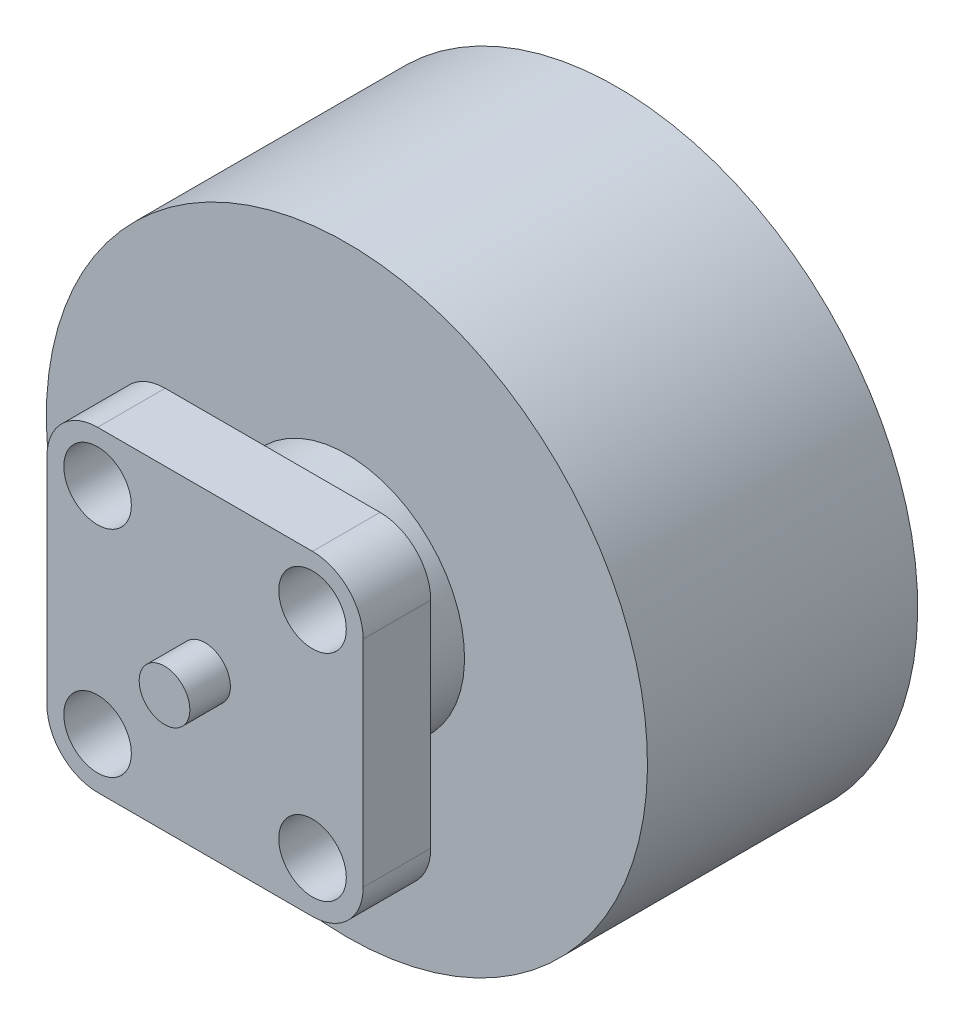
from build123d import *

# Parameters (mm, degrees)
SKETCH1_W           = 1.2
SKETCH1_H           = 0.75
SKETCH1_W_2         = 4.2
SKETCH1_W_3         = 8
SKETCH1_H_2         = 2.733563445
SKETCH2_W           = 9.36396103
SKETCH2_H           = 9.36396103
SKETCH2_R           = 1
BOSS_EXTRUDE1_DEPTH = 2
FILLET1_R           = 1.5
SKETCH3_R           = 1
CUT_EXTRUDE1_DEPTH  = 2


with BuildPart() as part:
    # Sketch1 → Revolve1 (revolve)
    with BuildSketch(Plane(origin=(0, 0, 0), x_dir=(0, 0, -1), z_dir=(1, 0, 0))):
        with Locations((-0.6, 0.375)):
            Rectangle(SKETCH1_W, SKETCH1_H)
        with Locations((2.1, 0.375)):
            Rectangle(SKETCH1_W_2, SKETCH1_H)
        with Locations((8.2, 0.375)):
            Rectangle(SKETCH1_W_3, SKETCH1_H)
        with Locations((14.3, 0.375)):
            Rectangle(SKETCH1_W_2, SKETCH1_H)
        Polygon((4.2, 3.483563445), (4.2, 0.75), (12.2, 0.75), (12.2, 8.9), (4.2, 8.9), align=None)
        with Locations((2.1, 2.116781722)):
            Rectangle(SKETCH1_W_2, SKETCH1_H_2)
    revolve(axis=Axis((0, 0, 1.2), (0, 0, -1)))

    # Sketch2 → Boss-Extrude1 (add)
    with BuildSketch(Plane.XY):
        Rectangle(SKETCH2_W, SKETCH2_H)
        with Locations((3.181980515, 3.181980515)):
            Circle(SKETCH2_R, mode=Mode.SUBTRACT)
        with Locations((3.181980515, -3.181980515)):
            Circle(SKETCH2_R, mode=Mode.SUBTRACT)
        with Locations((-3.181980515, -3.181980515)):
            Circle(SKETCH2_R, mode=Mode.SUBTRACT)
        with Locations((-3.181980515, 3.181980515)):
            Circle(SKETCH2_R, mode=Mode.SUBTRACT)
    extrude(amount=-BOSS_EXTRUDE1_DEPTH)

    # Fillet1
    fillet1_edges = [part.edges().sort_by_distance(p)[0] for p in [
        (4.681980515, 4.681980515, -1),
        (4.681980515, -4.681980515, -1),
        (-4.681980515, -4.681980515, -1),
        (-4.681980515, 4.681980515, -1),
    ]]
    fillet(fillet1_edges, radius=FILLET1_R)

    # Sketch3 → Cut-Extrude1 (cut)
    with BuildSketch(Plane(origin=(0, 0, -12.2), x_dir=(-1, 0, 0), z_dir=(0, 0, -1))):
        with Locations((0, 2.5)):
            Circle(SKETCH3_R)
        with Locations((2.5, 0)):
            Circle(SKETCH3_R)
        with Locations((0, -2.5)):
            Circle(SKETCH3_R)
        with Locations((-2.5, 0)):
            Circle(SKETCH3_R)
    extrude(amount=-CUT_EXTRUDE1_DEPTH, mode=Mode.SUBTRACT)


solid = part.part
